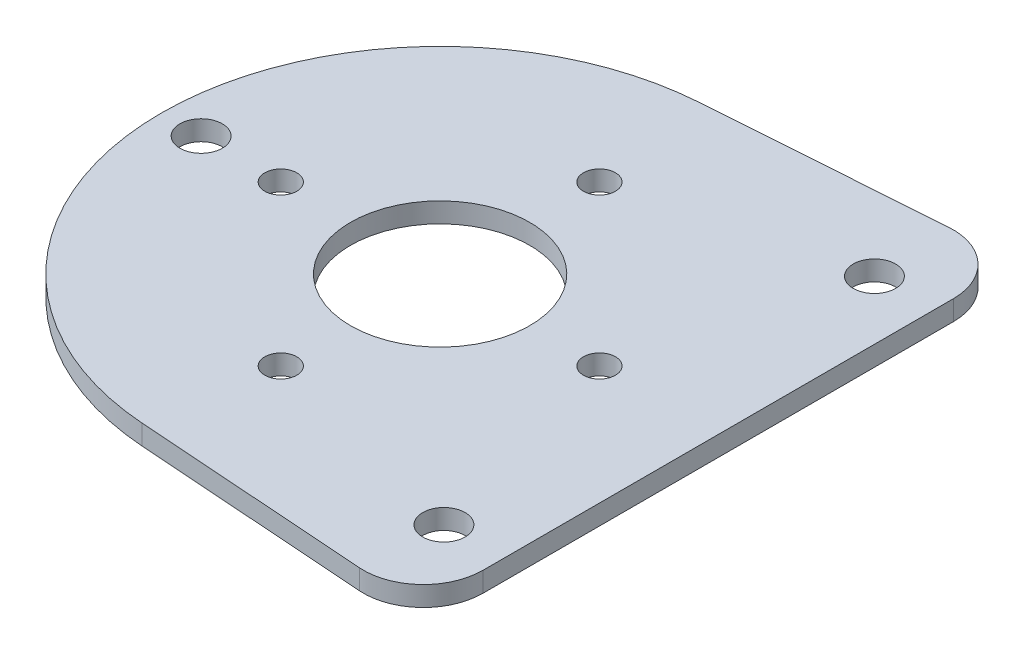
from build123d import *

# Parameters (mm, degrees)
SKETCH1_R               = 14.2875
SKETCH1_R_2             = 14.28115
BOSS_EXTRUDE1_DEPTH     = 3.175
F_10_CLEARANCE_HOLE1_D  = 5.1054
F_1_4_CLEARANCE_HOLE1_D = 6.7564
CUT_EXTRUDE2_DEPTH      = 4.175
FILLET2_R               = 9.525


with BuildPart() as part:
    # Sketch1 → Boss-Extrude1 (new body)
    with BuildSketch(Plane(origin=(0, 0, 0), x_dir=(1, 0, 0), z_dir=(0, 1, 0))):
        with BuildLine():
            Line((85.884602434, 50.671947857), (-3.15409287, 44.337954375))
            ThreePointArc((-3.15409287, 44.337954375), (-44.45, 0), (-3.15409287, -44.337954375))
            Line((-3.15409287, -44.337954375), (85.884602434, -50.671947857))
            ThreePointArc((85.884602434, -50.671947857), (140.28928, 0), (85.884602434, 50.671947857))
        make_face()
        with Locations((89.48928, 0)):
            Circle(SKETCH1_R, mode=Mode.SUBTRACT)
        Circle(SKETCH1_R_2, mode=Mode.SUBTRACT)
    extrude(amount=BOSS_EXTRUDE1_DEPTH)

    # #10 Clearance Hole1 (through all)
    with Locations(Plane(origin=(0, 3.175, 0), x_dir=(1, 0, 0), z_dir=(0, 1, 0))):
        with Locations((0, 25.4), (25.4, 0), (0, -25.4), (-25.4, 0)):
            Hole(F_10_CLEARANCE_HOLE1_D / 2)

    # 1/4 Clearance Hole1 (through all)
    with Locations(Plane(origin=(0, 3.175, 0), x_dir=(1, 0, 0), z_dir=(0, 1, 0))):
        with Locations((54.56428, 34.925), (54.56428, -34.925), (114.88928, 25.4), (114.88928, -25.4), (-38.1, 0), (34.925, 34.314713318), (34.925, -34.314713318)):
            Hole(F_1_4_CLEARANCE_HOLE1_D / 2)

    # Sketch7 → Cut-Extrude2 (cut, through all)
    with BuildSketch(Plane(origin=(0, 3.175, 0), x_dir=(1, 0, 0), z_dir=(0, 1, 0))):
        Polygon((44.323, 47.715357826), (140.28928, 54.542162621), (140.28928, -54.542162621), (44.323, -47.715357826), align=None)
    extrude(amount=-CUT_EXTRUDE2_DEPTH, mode=Mode.SUBTRACT)

    # Fillet2
    fillet2_edges = [part.edges().sort_by_distance(p)[0] for p in [
        (44.323, 1.5875, -47.715357826),
        (44.323, 1.5875, 47.715357826),
    ]]
    fillet(fillet2_edges, radius=FILLET2_R)


solid = part.part
